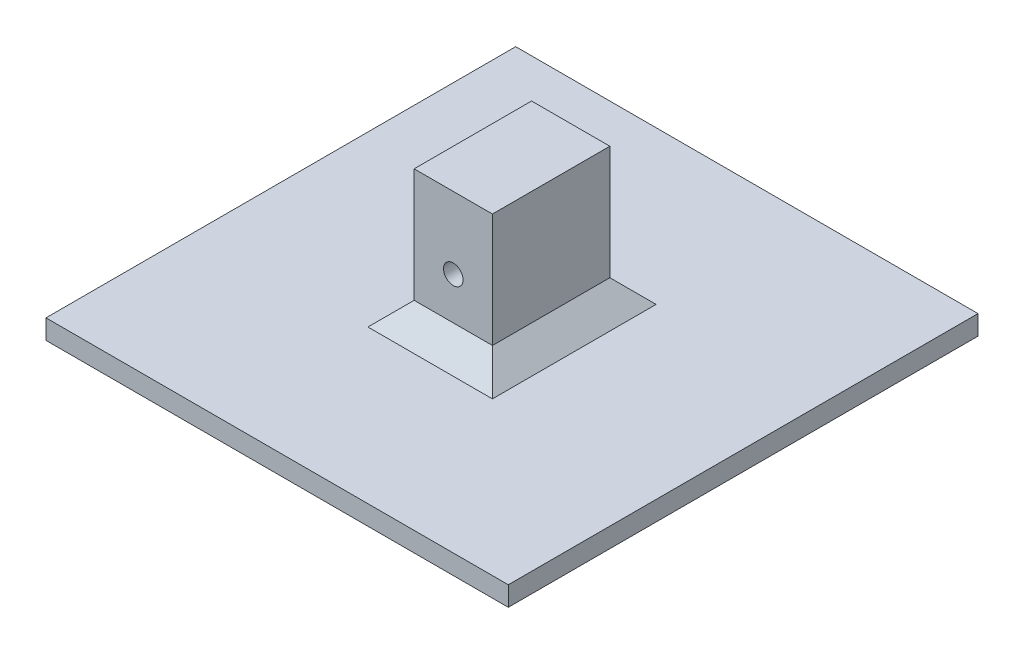
from build123d import *

# Parameters (mm, degrees)
BOSS_EXTRUDE1_DEPTH         = 12.7
BOSS_EXTRUDE1_DEPTH_BACK    = 12.7
F_1_4_0_25_DIAMETER_HOLE1_D = 6.35
BOSS_EXTRUDE2_DEPTH         = 75
BOSS_EXTRUDE2_DEPTH_BACK    = 75
SKETCH6_W                   = 152.4
SKETCH6_H                   = 6.35
CHAMFER1_SIZE               = 7.5


with BuildPart() as part:
    # Sketch-Profile → Boss-Extrude1 (new, two sides: drawn at the far end of the back side and taken through both)
    with BuildSketch(Plane(origin=(0, 0, 0), x_dir=(0, 0, -1), z_dir=(1, 0, 0)).offset(-BOSS_EXTRUDE1_DEPTH_BACK)):
        Polygon((-76.2, 6.35), (-76.2, 0), (76.2, 0), (76.2, 6.35), (19.05, 6.35), (19.05, 50.8), (-19.05, 50.8), (-19.05, 6.35), align=None)
    extrude(amount=BOSS_EXTRUDE1_DEPTH + BOSS_EXTRUDE1_DEPTH_BACK)

    # 1_4 _0.25_ Diameter Hole1 (through all)
    with Locations(Plane.XY.offset(19.05)):
        with Locations((0, 27.5181)):
            Hole(F_1_4_0_25_DIAMETER_HOLE1_D / 2)

    # Sketch6 → Boss-Extrude2 (add, two sides: drawn at the far end of the back side and taken through both)
    with BuildSketch(Plane(origin=(0, 0, 0), x_dir=(0, 0, -1), z_dir=(1, 0, 0)).offset(-BOSS_EXTRUDE2_DEPTH_BACK)):
        with Locations((0, 3.175)):
            Rectangle(SKETCH6_W, SKETCH6_H)
    extrude(amount=BOSS_EXTRUDE2_DEPTH + BOSS_EXTRUDE2_DEPTH_BACK)

    # Chamfer1
    chamfer1_edges = [part.edges().sort_by_distance(p)[0] for p in [
        (0, 6.35, 19.05),
        (-12.7, 6.35, 0),
        (0, 6.35, -19.05),
        (12.7, 6.35, 0),
    ]]
    chamfer(chamfer1_edges, length=CHAMFER1_SIZE)


solid = part.part
